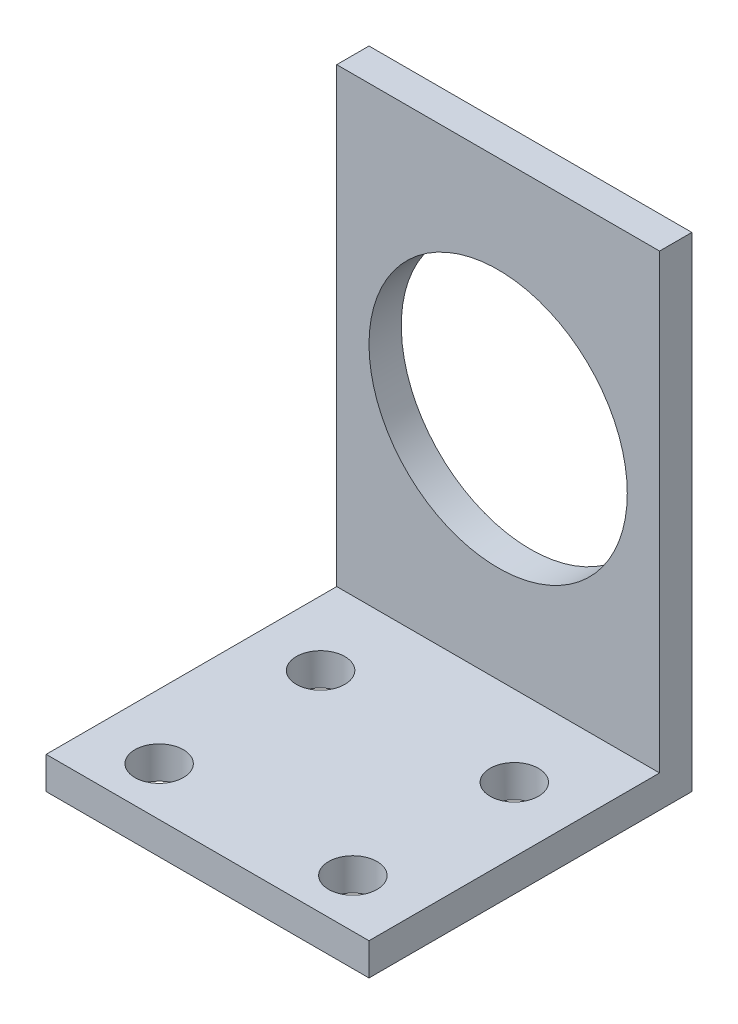
from build123d import *

# Parameters (mm, degrees)
EXTRUDE_1_DEPTH     = 20
CUT_EXTRUDE_1_REACH = 5
SKETCH_2_R          = 8
CUT_EXTRUDE_2_REACH = 5
SKETCH_3_R          = 1.5
SKETCH_6_W          = 20
SKETCH_6_H          = 3
EXTRUDE_2_DEPTH     = 5
SKETCH_8_W          = 20
SKETCH_8_H          = 27
CUT_EXTRUDE_5_DEPTH = 1
SKETCH_10_W         = 20
SKETCH_10_H         = 3
CUT_EXTRUDE_7_DEPTH = 18
SKETCH_11_W         = 20
SKETCH_11_H         = 18
CUT_EXTRUDE_8_DEPTH = 1
SKETCH_12_R         = 1.5
CUT_EXTRUDE_9_DEPTH = 2


with BuildPart() as part:
    # 草图1 → 凸台-拉伸1 (new body)
    with BuildSketch(Plane(origin=(0, 0, 0), x_dir=(0, 0, -1), z_dir=(1, 0, 0))):
        Polygon((0, 0), (0, 22), (3, 22), (3, -3), (-35, -3), (-35, 0), align=None)
    extrude(amount=EXTRUDE_1_DEPTH)

    # 草图2 → 切除-拉伸1 (cut, up to next)
    with BuildSketch(Plane.XY, mode=Mode.PRIVATE) as cut_extrude_1_sk1:
        with Locations((10, 13)):
            Circle(SKETCH_2_R)
    cut_extrude_1_tool1 = extrude(cut_extrude_1_sk1.sketch, amount=-CUT_EXTRUDE_1_REACH, mode=Mode.PRIVATE) & part.part
    add(cut_extrude_1_tool1.solids().sort_by_distance((10, 13, 0))[0], mode=Mode.SUBTRACT)

    # 草图3 → 切除-拉伸2 (cut, up to next)
    with BuildSketch(Plane(origin=(0, 0, 0), x_dir=(1, 0, 0), z_dir=(0, 1, 0)), mode=Mode.PRIVATE) as cut_extrude_2_sk1:
        with Locations((4, -4)):
            Circle(SKETCH_3_R)
    cut_extrude_2_tool1 = extrude(cut_extrude_2_sk1.sketch, amount=-CUT_EXTRUDE_2_REACH, mode=Mode.PRIVATE) & part.part
    add(cut_extrude_2_tool1.solids().sort_by_distance((4, 0, 4))[0], mode=Mode.SUBTRACT)
    # 草图3 → 切除-拉伸2 (cut, up to next)
    with BuildSketch(Plane(origin=(0, 0, 0), x_dir=(1, 0, 0), z_dir=(0, 1, 0)), mode=Mode.PRIVATE) as cut_extrude_2_sk2:
        with Locations((16, -4)):
            Circle(SKETCH_3_R)
    cut_extrude_2_tool2 = extrude(cut_extrude_2_sk2.sketch, amount=-CUT_EXTRUDE_2_REACH, mode=Mode.PRIVATE) & part.part
    add(cut_extrude_2_tool2.solids().sort_by_distance((16, 0, 4))[0], mode=Mode.SUBTRACT)

    # 草图6 → 凸台-拉伸2 (add)
    with BuildSketch(Plane(origin=(0, 22, 0), x_dir=(1, 0, 0), z_dir=(0, 1, 0))):
        with Locations((10, 1.5)):
            Rectangle(SKETCH_6_W, SKETCH_6_H)
    extrude(amount=EXTRUDE_2_DEPTH)

    # 草图8 → 切除-拉伸5 (cut)
    with BuildSketch(Plane.XY):
        with Locations((10, 13.5)):
            Rectangle(SKETCH_8_W, SKETCH_8_H)
    extrude(amount=-CUT_EXTRUDE_5_DEPTH, mode=Mode.SUBTRACT)

    # 草图10 → 切除-拉伸7 (cut)
    with BuildSketch(Plane.XY.offset(35)):
        with Locations((10, -1.5)):
            Rectangle(SKETCH_10_W, SKETCH_10_H)
    extrude(amount=-CUT_EXTRUDE_7_DEPTH, mode=Mode.SUBTRACT)

    # 草图11 → 切除-拉伸8 (cut)
    with BuildSketch(Plane(origin=(0, 0, 0), x_dir=(1, 0, 0), z_dir=(0, 1, 0))):
        with Locations((10, -8)):
            Rectangle(SKETCH_11_W, SKETCH_11_H)
    extrude(amount=-CUT_EXTRUDE_8_DEPTH, mode=Mode.SUBTRACT)

    # 草图12 → 切除-拉伸9 (cut)
    with BuildSketch(Plane(origin=(0, -1, 0), x_dir=(1, 0, 0), z_dir=(0, 1, 0))):
        with Locations((4, -14)):
            Circle(SKETCH_12_R)
        with Locations((16, -14)):
            Circle(SKETCH_12_R)
    extrude(amount=-CUT_EXTRUDE_9_DEPTH, mode=Mode.SUBTRACT)


solid = part.part
